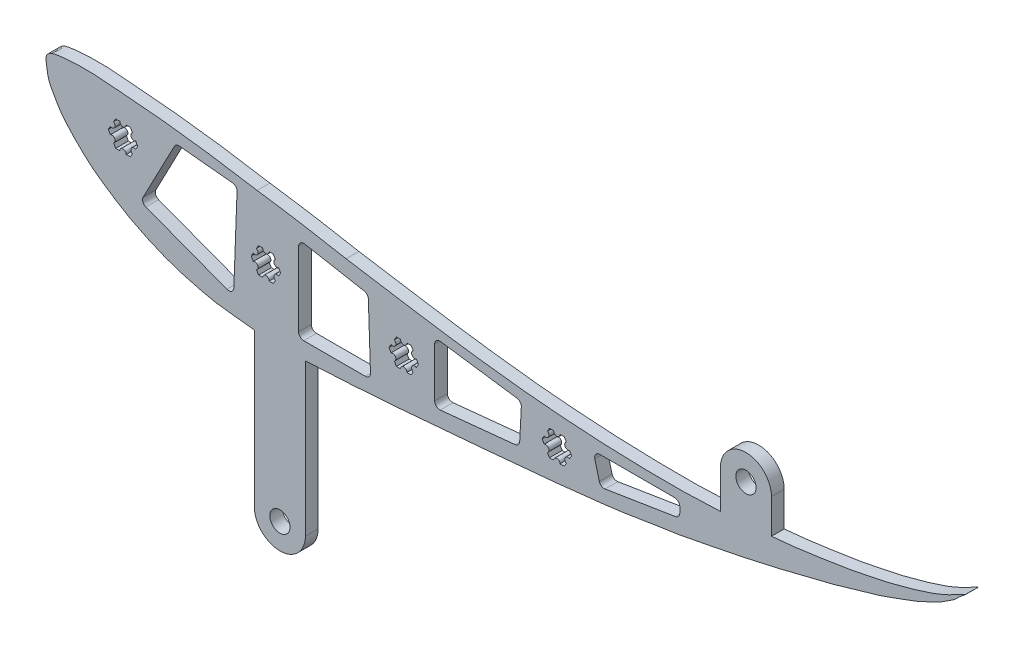
from build123d import *

# Parameters (mm, degrees)
BOSS_EXTRUDE1_DEPTH = 6.35
SKETCH4_R           = 5.0419
CUT_EXTRUDE3_DEPTH  = 381


with BuildPart() as part:
    # Sketch1 → Boss-Extrude1 (new body)
    with BuildSketch(Plane.XY):
        with BuildLine():
            Line((86.843236333, 28.852341554), (86.843236333, -47.347658446))
            ThreePointArc((86.843236333, -47.347658446), (99.543236333, -60.047658446), (112.243236333, -47.347658446))
            Line((112.243236333, -47.347658446), (112.243236333, 28.214453304))
            add(Edge.make_bspline(
                [(284.199234458, 44.142295139), (279.294395814, 43.357842002), (268.909518031, 41.574011521), (251.075001435, 39.596728872), (229.388616994, 37.203012777), (203.745382629, 34.933554815), (177.499705437, 32.720447696), (150.343263706, 30.344574846), (129.641800793, 29.067926494), (115.906293067, 28.35375286), (112.243236333, 28.214453304)],
                knots=[0, 0, 0, 0, 0.015541428, 0.0329644, 0.056129615, 0.083825782, 0.113482008, 0.138675058, 0.168699881, 0.179792425, 0.179792425, 0.179792425, 0.179792425], degree=3))
            add(Edge.make_bspline(
                [(284.199234458, 44.142295139), (298.298890591, 46.026311398), (312.219332977, 48.964745329)],
                knots=[0, 0, 0, 1, 1, 1], degree=2))
            add(Edge.make_bspline(
                [(344.183466694, 68.589167204), (345.960077228, 68.765717475), (351.023604598, 69.276320161), (359.067906447, 70.049570339), (367.896874578, 71.420704301), (377.007425502, 72.883057797), (386.227823421, 74.138373924), (395.367743176, 76.385575861), (403.564697097, 77.907582397), (410.735250399, 79.953005658), (417.114285798, 81.687412008), (422.732680223, 83.591992804), (427.164087313, 85.094079009), (431.171696898, 86.937153076), (434.607250511, 88.392786361), (443.123217376, 93.275688905), (437.255094337, 89.117703468), (435.279778464, 86.561175616), (431.573501891, 84.704524529), (428.464842726, 82.201032813), (424.134266462, 80.398696308), (419.425258521, 77.797857577), (414.105440345, 75.713007702), (408.77839072, 73.798734141), (403.684867312, 72.029145889), (396.961540144, 69.466067962), (387.343622202, 67.136732033), (376.830663922, 63.608926675), (365.24798357, 60.901656463), (354.754672426, 58.255886458), (344.650791698, 55.720154361), (336.670341174, 53.941801639), (329.235250959, 52.381752299), (321.327868228, 50.67683374), (315.380943803, 49.564945959), (312.219332977, 48.964745329)],
                knots=[0.723925671, 0.723925671, 0.723925671, 0.723925671, 0.729512264, 0.739849456, 0.749207405, 0.757460827, 0.768730363, 0.778293847, 0.786890263, 0.794802236, 0.801604534, 0.807594637, 0.813291486, 0.816448103, 0.82085612, 0.827926825, 0.831665363, 0.835751441, 0.83945205, 0.844046018, 0.848300781, 0.853998897, 0.860892335, 0.866131986, 0.871720144, 0.8777654, 0.888628081, 0.902630202, 0.912436555, 0.9258276, 0.936499298, 0.945030841, 0.951410342, 0.960272134, 0.970341344, 0.970341344, 0.970341344, 0.970341344], degree=3))
            Line((344.183466694, 68.589167204), (344.183466694, 85.66645713))
            ThreePointArc((344.183466694, 85.66645713), (331.483466694, 98.36645713), (318.783466694, 85.66645713))
            Line((318.783466694, 85.66645713), (318.783466694, 66.61645713))
            add(Edge.make_bspline(
                [(132.497155304, 82.352564082), (138.660299986, 81.364772696), (150.055716295, 79.576696099), (168.256858053, 76.617688262), (186.559493812, 73.857794613), (206.695059336, 71.20791695), (225.195546149, 69.114961125), (244.068606399, 67.656695297), (262.59445245, 66.476567979), (282.222526993, 65.926744761), (300.996093327, 65.813021246), (313.031712183, 66.3055652), (318.783466694, 66.61645713)],
                knots=[0.501939517, 0.501939517, 0.501939517, 0.501939517, 0.521471314, 0.538034042, 0.559642198, 0.579387607, 0.601584161, 0.617891309, 0.638616798, 0.65966521, 0.679327658, 0.697349837, 0.697349837, 0.697349837, 0.697349837], degree=3))
            add(Edge.make_bspline(
                [(88.218059616, 89.662129085), (110.445034344, 86.541787398), (132.497155304, 82.352564082)],
                knots=[0, 0, 0, 1, 1, 1], degree=2))
            add(Edge.make_bspline(
                [(86.843236333, 28.852341554), (83.096028055, 29.23059461), (75.456196554, 30.010523718), (67.310215778, 30.977463397), (60.237997702, 32.582425676), (53.935534164, 34.232006507), (47.113877589, 36.133551764), (41.431363444, 38.368275103), (36.428765086, 40.445297648), (32.069587813, 42.402430324), (27.662400688, 44.667790264), (23.104789622, 46.965799851), (18.731687609, 49.734821084), (12.723675255, 53.669846892), (5.809434729, 58.404883079), (-1.037305304, 65.077409289), (-6.51320076, 70.614178991), (-10.540658158, 76.008047875), (-12.880350205, 80.406543609), (-15.167480815, 84.128221175), (-16.123087236, 87.961419413), (-16.605403063, 91.507477621), (-17.515788121, 97.582670832), (-2.852582554, 99.497127174), (9.154054709, 99.213304724), (23.433217875, 97.797752429), (34.6859051, 97.019819773), (46.592767258, 95.707761604), (58.472171701, 94.254609297), (72.666253463, 92.219697635), (81.966547707, 90.697946158), (88.218059616, 89.662129085)],
                knots=[0.207444958, 0.207444958, 0.207444958, 0.207444958, 0.219542262, 0.228138621, 0.234034354, 0.242053809, 0.248579804, 0.256163175, 0.261140779, 0.265532514, 0.271109358, 0.27664698, 0.281492237, 0.287290347, 0.29913904, 0.307609474, 0.317155492, 0.323491488, 0.328573172, 0.332744167, 0.337105386, 0.340676482, 0.344320779, 0.354257826, 0.374751268, 0.388233645, 0.397827061, 0.410265792, 0.425639153, 0.43529959, 0.45512849, 0.45512849, 0.45512849, 0.45512849], degree=3))
        make_face()
    extrude(amount=BOSS_EXTRUDE1_DEPTH)

    # Sketch4 → Cut-Extrude3 (cut)
    with BuildSketch(Plane.XY.offset(6.35)):
        with Locations((99.543236333, -47.347658446)):
            Circle(SKETCH4_R)
        with Locations((331.483466694, 85.66645713)):
            Circle(SKETCH4_R)
        with BuildLine():
            Line((88.931300118, 66.243537573), (91.009974327, 66.243537573))
            ThreePointArc((91.009974327, 66.243537573), (92.597474327, 64.656037573), (94.184974327, 66.243537573))
            Line((94.184974327, 66.243537573), (96.263648536, 66.243537573))
            Line((96.263648536, 66.243537573), (97.302985641, 64.443352902))
            ThreePointArc((97.302985641, 64.443352902), (96.721920833, 62.274787434), (98.890486301, 61.693722626))
            Line((98.890486301, 61.693722626), (99.929823515, 59.893537766))
            Line((99.929823515, 59.893537766), (98.89048641, 58.093353094))
            ThreePointArc((98.89048641, 58.093353094), (96.721921082, 57.512287766), (97.30298641, 55.343722437))
            Line((97.30298641, 55.343722437), (96.263649306, 53.543537766))
            Line((96.263649306, 53.543537766), (94.184975096, 53.543537766))
            ThreePointArc((94.184975096, 53.543537766), (92.597475, 55.131037573), (91.009975096, 53.543537573))
            Line((91.009975096, 53.543537573), (88.931300887, 53.543537573))
            Line((88.931300887, 53.543537573), (87.891963673, 55.343722182))
            ThreePointArc((87.891963673, 55.343722182), (88.47302887, 57.512287545), (86.304463507, 58.093352743))
            Line((86.304463507, 58.093352743), (85.265126293, 59.893537351))
            Line((85.265126293, 59.893537351), (86.304463288, 61.693722086))
            ThreePointArc((86.304463288, 61.693722086), (88.473028582, 62.274787545), (87.891963122, 64.443352839))
            Line((87.891963122, 64.443352839), (88.931300118, 66.243537573))
        make_face()
        with BuildLine():
            Line((17.811300118, 85.293537573), (19.889974327, 85.293537573))
            ThreePointArc((19.889974327, 85.293537573), (21.477474327, 83.706037573), (23.064974327, 85.293537573))
            Line((23.064974327, 85.293537573), (25.143648536, 85.293537573))
            Line((25.143648536, 85.293537573), (26.182985641, 83.493352902))
            ThreePointArc((26.182985641, 83.493352902), (25.601920833, 81.324787434), (27.770486301, 80.743722626))
            Line((27.770486301, 80.743722626), (28.809823515, 78.943537766))
            Line((28.809823515, 78.943537766), (27.77048641, 77.143353094))
            ThreePointArc((27.77048641, 77.143353094), (25.601921082, 76.562287766), (26.18298641, 74.393722437))
            Line((26.18298641, 74.393722437), (25.143649306, 72.593537766))
            Line((25.143649306, 72.593537766), (23.064975096, 72.593537766))
            ThreePointArc((23.064975096, 72.593537766), (21.477475, 74.181037573), (19.889975096, 72.593537573))
            Line((19.889975096, 72.593537573), (17.811300887, 72.593537573))
            Line((17.811300887, 72.593537573), (16.771963673, 74.393722182))
            ThreePointArc((16.771963673, 74.393722182), (17.35302887, 76.562287545), (15.184463507, 77.143352743))
            Line((15.184463507, 77.143352743), (14.145126293, 78.943537351))
            Line((14.145126293, 78.943537351), (15.184463288, 80.743722086))
            ThreePointArc((15.184463288, 80.743722086), (17.353028582, 81.324787545), (16.771963122, 83.493352839))
            Line((16.771963122, 83.493352839), (17.811300118, 85.293537573))
        make_face()
        with BuildLine():
            Line((233.711300118, 59.893537573), (235.789974327, 59.893537573))
            ThreePointArc((235.789974327, 59.893537573), (237.377474327, 58.306037573), (238.964974327, 59.893537573))
            Line((238.964974327, 59.893537573), (241.043648536, 59.893537573))
            Line((241.043648536, 59.893537573), (242.082985641, 58.093352902))
            ThreePointArc((242.082985641, 58.093352902), (241.501920833, 55.924787434), (243.670486301, 55.343722626))
            Line((243.670486301, 55.343722626), (244.709823515, 53.543537766))
            Line((244.709823515, 53.543537766), (243.67048641, 51.743353094))
            ThreePointArc((243.67048641, 51.743353094), (241.501921082, 51.162287766), (242.08298641, 48.993722437))
            Line((242.08298641, 48.993722437), (241.043649306, 47.193537766))
            Line((241.043649306, 47.193537766), (238.964975096, 47.193537766))
            ThreePointArc((238.964975096, 47.193537766), (237.377475, 48.781037573), (235.789975096, 47.193537573))
            Line((235.789975096, 47.193537573), (233.711300887, 47.193537573))
            Line((233.711300887, 47.193537573), (232.671963673, 48.993722182))
            ThreePointArc((232.671963673, 48.993722182), (233.25302887, 51.162287545), (231.084463507, 51.743352743))
            Line((231.084463507, 51.743352743), (230.045126293, 53.543537351))
            Line((230.045126293, 53.543537351), (231.084463288, 55.343722086))
            ThreePointArc((231.084463288, 55.343722086), (233.253028582, 55.924787545), (232.671963122, 58.093352839))
            Line((232.671963122, 58.093352839), (233.711300118, 59.893537573))
        make_face()
        with BuildLine():
            Line((157.511300118, 61.163537573), (159.589974327, 61.163537573))
            ThreePointArc((159.589974327, 61.163537573), (161.177474327, 59.576037573), (162.764974327, 61.163537573))
            Line((162.764974327, 61.163537573), (164.843648536, 61.163537573))
            Line((164.843648536, 61.163537573), (165.882985641, 59.363352902))
            ThreePointArc((165.882985641, 59.363352902), (165.301920833, 57.194787434), (167.470486301, 56.613722626))
            Line((167.470486301, 56.613722626), (168.509823515, 54.813537766))
            Line((168.509823515, 54.813537766), (167.47048641, 53.013353094))
            ThreePointArc((167.47048641, 53.013353094), (165.301921082, 52.432287766), (165.88298641, 50.263722437))
            Line((165.88298641, 50.263722437), (164.843649306, 48.463537766))
            Line((164.843649306, 48.463537766), (162.764975096, 48.463537766))
            ThreePointArc((162.764975096, 48.463537766), (161.177475, 50.051037573), (159.589975096, 48.463537573))
            Line((159.589975096, 48.463537573), (157.511300887, 48.463537573))
            Line((157.511300887, 48.463537573), (156.471963673, 50.263722182))
            ThreePointArc((156.471963673, 50.263722182), (157.05302887, 52.432287545), (154.884463507, 53.013352743))
            Line((154.884463507, 53.013352743), (153.845126293, 54.813537351))
            Line((153.845126293, 54.813537351), (154.884463288, 56.613722086))
            ThreePointArc((154.884463288, 56.613722086), (157.053028582, 57.194787545), (156.471963122, 59.363352839))
            Line((156.471963122, 59.363352839), (157.511300118, 61.163537573))
        make_face()
        with BuildLine():
            Line((31.501207482, 58.37669779), (47.032113751, 88.081016492))
            ThreePointArc((47.032113751, 88.081016492), (48.076445172, 89.139261035), (49.534182489, 89.431684603))
            Line((49.534182489, 89.431684603), (75.93058222, 86.808602351))
            ThreePointArc((75.93058222, 86.808602351), (77.593752589, 85.950453195), (78.217633108, 84.185990458))
            Line((78.217633108, 84.185990458), (76.631821885, 41.843273018))
            ThreePointArc((76.631821885, 41.843273018), (75.497981954, 39.821894696), (73.194863199, 39.56265096))
            Line((73.194863199, 39.56265096), (32.853368422, 54.824131949))
            ThreePointArc((32.853368422, 54.824131949), (31.378241648, 56.296285615), (31.501207482, 58.37669779))
        make_face()
        with BuildLine():
            Line((111.858309541, 78.393902518), (141.485442222, 72.962296795))
            ThreePointArc((141.485442222, 72.962296795), (142.950940478, 72.12274223), (143.565962065, 70.549756072))
            Line((143.565962065, 70.549756072), (144.628770085, 39.112135773))
            ThreePointArc((144.628770085, 39.112135773), (143.916361615, 37.260866924), (142.090220332, 36.486315313))
            Line((142.090220332, 36.486315313), (111.400279631, 36.486315313))
            ThreePointArc((111.400279631, 36.486315313), (109.604228407, 37.230264089), (108.860279631, 39.026315313))
            Line((108.860279631, 39.026315313), (108.860279631, 75.895541334))
            ThreePointArc((108.860279631, 75.895541334), (109.774210132, 77.846822448), (111.858309541, 78.393902518))
        make_face()
        with BuildLine():
            Line((179.473393864, 70.165192722), (217.50482476, 64.769576264))
            ThreePointArc((217.50482476, 64.769576264), (219.108331349, 63.86995645), (219.68467301, 62.123995546))
            Line((219.68467301, 62.123995546), (218.890378913, 46.71578744))
            ThreePointArc((218.890378913, 46.71578744), (218.192789678, 45.094545708), (216.607247121, 44.319232678))
            Line((216.607247121, 44.319232678), (179.370110323, 40.58420072))
            ThreePointArc((179.370110323, 40.58420072), (177.412540188, 41.227973149), (176.576610312, 43.111519011))
            Line((176.576610312, 43.111519011), (176.576610312, 67.650375533))
            ThreePointArc((176.576610312, 67.650375533), (177.451472213, 69.568425352), (179.473393864, 70.165192722))
        make_face()
        with BuildLine():
            Line((258.751236774, 61.163537573), (296.003687002, 61.163537573))
            ThreePointArc((296.003687002, 61.163537573), (297.799738226, 60.419588797), (298.543687002, 58.623537573))
            Line((298.543687002, 58.623537573), (298.543687002, 55.707363059))
            ThreePointArc((298.543687002, 55.707363059), (297.937199117, 54.060204626), (296.407363457, 53.199645906))
            Line((296.407363457, 53.199645906), (261.377375447, 47.560739881))
            ThreePointArc((261.377375447, 47.560739881), (259.584877656, 47.941775277), (258.515299797, 49.429807368))
            Line((258.515299797, 49.429807368), (256.292837579, 57.984887907))
            ThreePointArc((256.292837579, 57.984887907), (256.742036666, 60.177472876), (258.751236774, 61.163537573))
        make_face()
    extrude(amount=-CUT_EXTRUDE3_DEPTH, mode=Mode.SUBTRACT)


solid = part.part
